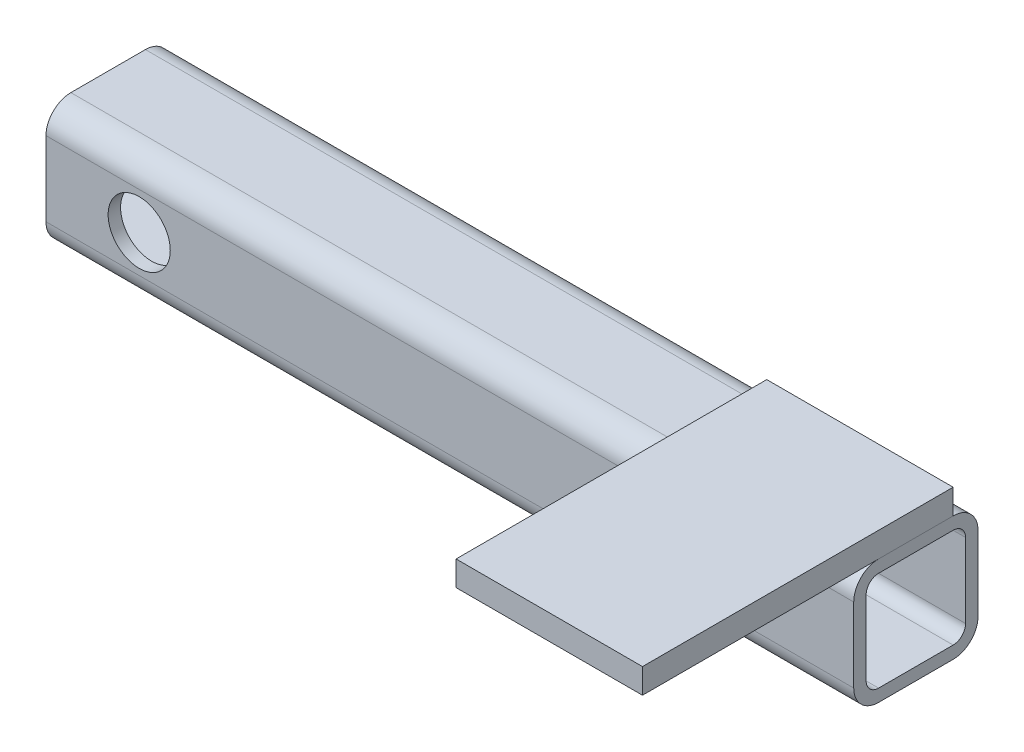
from build123d import *

# Parameters (mm, degrees)
STRUCTURAL_MEMBER1_DEPTH = 130
SKETCH12_R               = 5
CUT_EXTRUDE1_DEPTH       = 35
SKETCH13_W               = 30
SKETCH13_H               = 50
BOSS_EXTRUDE1_DEPTH      = 4


with BuildPart() as part:
    # Sketch11 → Structural Member1 (new body)
    with BuildSketch(Plane.YZ):
        with BuildLine():
            Line((-6, -10), (6, -10))
            ThreePointArc((6, -10), (8.828427125, -8.828427125), (10, -6))
            Line((10, -6), (10, 6))
            ThreePointArc((10, 6), (8.828427125, 8.828427125), (6, 10))
            Line((6, 10), (-6, 10))
            ThreePointArc((-6, 10), (-8.828427125, 8.828427125), (-10, 6))
            Line((-10, 6), (-10, -6))
            ThreePointArc((-10, -6), (-8.828427125, -8.828427125), (-6, -10))
        make_face()
        with BuildLine():
            Line((-6, -8), (6, -8))
            ThreePointArc((6, -8), (7.414213562, -7.414213562), (8, -6))
            Line((8, -6), (8, 6))
            ThreePointArc((8, 6), (7.414213562, 7.414213562), (6, 8))
            Line((6, 8), (-6, 8))
            ThreePointArc((-6, 8), (-7.414213562, 7.414213562), (-8, 6))
            Line((-8, 6), (-8, -6))
            ThreePointArc((-8, -6), (-7.414213562, -7.414213562), (-6, -8))
        make_face(mode=Mode.SUBTRACT)
    extrude(amount=STRUCTURAL_MEMBER1_DEPTH)

    # Sketch12 → Cut-Extrude1 (cut)
    with BuildSketch(Plane.XY.offset(10)):
        with Locations((15, 0)):
            Circle(SKETCH12_R)
    extrude(amount=-CUT_EXTRUDE1_DEPTH, mode=Mode.SUBTRACT)


with BuildPart() as body_2:
    # Sketch13 → Boss-Extrude1 (new body)
    with BuildSketch(Plane(origin=(0, 10, 0), x_dir=(1, 0, 0), z_dir=(0, 1, 0))):
        with Locations((115, -19)):
            Rectangle(SKETCH13_W, SKETCH13_H)
    extrude(amount=BOSS_EXTRUDE1_DEPTH)


solid = Compound([part.part, body_2.part])
